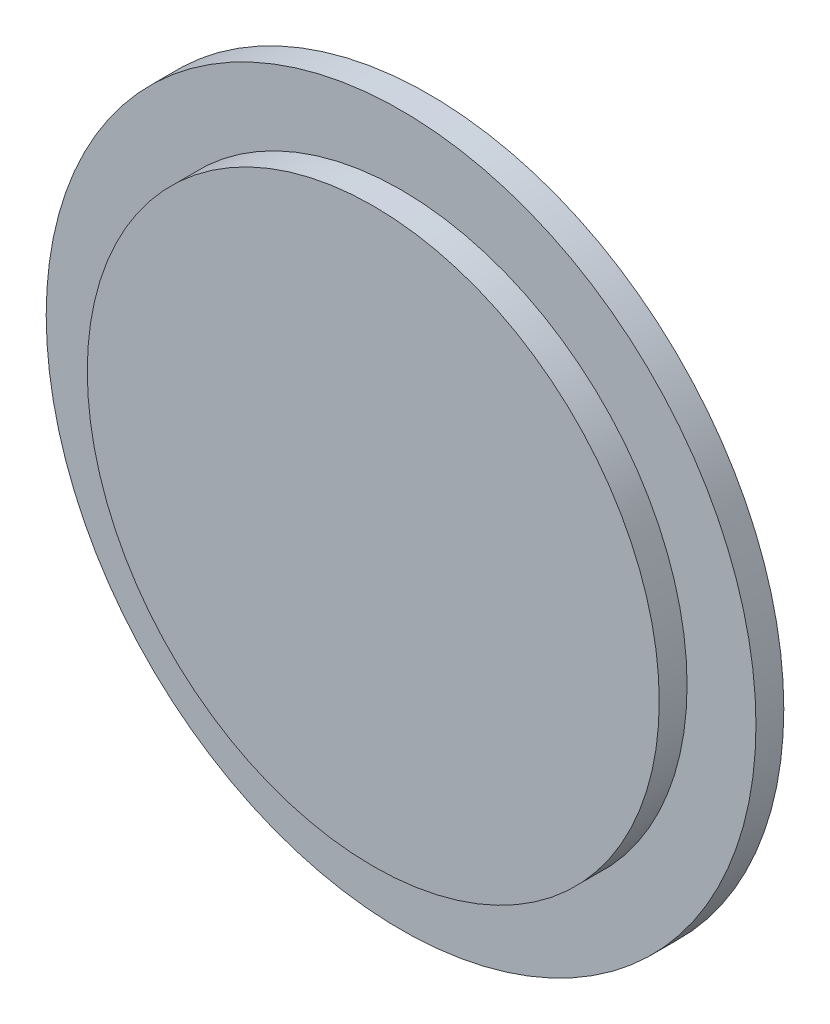
from build123d import *

# Parameters (mm, degrees)
SKETCH1_R           = 25.5
BOSS_EXTRUDE1_DEPTH = 2
SKETCH2_R           = 20.55
BOSS_EXTRUDE2_DEPTH = 2


with BuildPart() as part:
    # Sketch1 → Boss-Extrude1 (new body)
    with BuildSketch(Plane.XY):
        Circle(SKETCH1_R)
    extrude(amount=BOSS_EXTRUDE1_DEPTH)

    # Sketch2 → Boss-Extrude2 (add)
    with BuildSketch(Plane.XY.offset(2)):
        Circle(SKETCH2_R)
    extrude(amount=BOSS_EXTRUDE2_DEPTH)


solid = part.part
